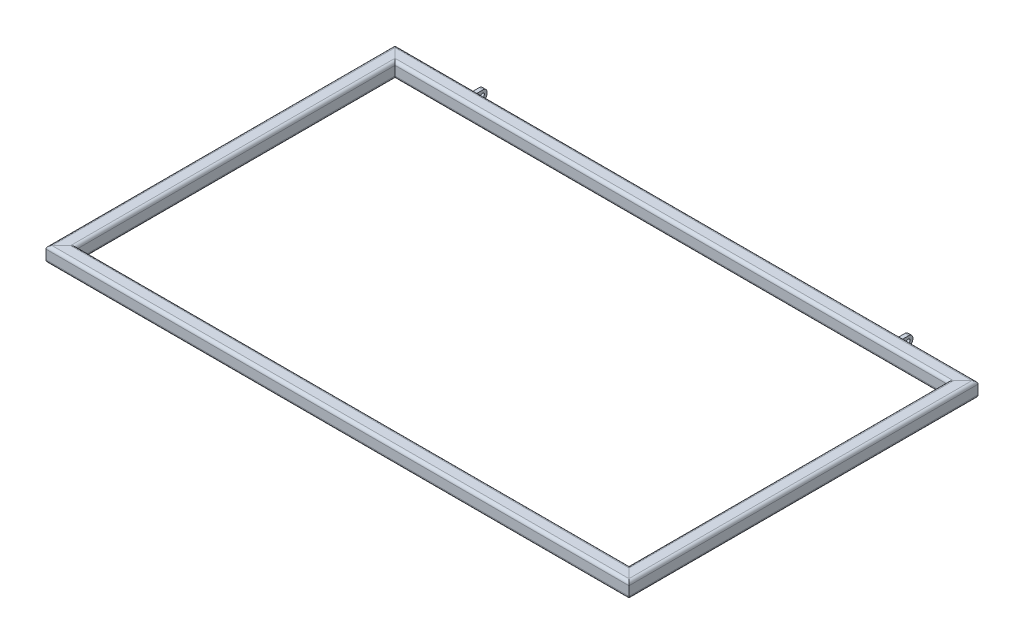
from build123d import *

# Parameters (mm, degrees)
SQUARE_TUBE_CONFIGURED_20_X_20_X_2_1_DEPTH      = 785.142135624
SQUARE_TUBE_CONFIGURED_20_X_20_X_2_1_DEPTH_BACK = 25.142135624
SQUARE_TUBE_CONFIGURED_20_X_20_X_2_1_2_DEPTH    = 505.284271247
SQUARE_TUBE_CONFIGURED_20_X_20_X_2_1_3_DEPTH    = 810.284271247
SQUARE_TUBE_CONFIGURED_20_X_20_X_2_1_4_DEPTH    = 505.284271247
SKETCH12_W                                      = 5
SKETCH12_H                                      = 12
BOSS_EXTRUDE1_DEPTH                             = 15
BOSS_EXTRUDE1_2_DEPTH                           = 15
FILLET1_R                                       = 5
FILLET2_R                                       = 5
SKETCH13_R                                      = 2.5
CUT_EXTRUDE1_DEPTH                              = 699.52075846
CUT_EXTRUDE1_DEPTH_BACK                         = 699.52075846


with BuildPart() as part:
    # Sketch11 → Square tube - configured 20 X 20 X 2(1) (new, two sides)
    with BuildSketch(Plane(origin=(380, 0, -217.5), x_dir=(0, 0, 1), z_dir=(-1, 0, 0))) as square_tube_configured_20_x_20_x_2_1_sk:
        with BuildLine():
            Line((-6, -10), (6, -10))
            ThreePointArc((6, -10), (8.828427125, -8.828427125), (10, -6))
            Line((10, -6), (10, 6))
            ThreePointArc((10, 6), (8.828427125, 8.828427125), (6, 10))
            Line((6, 10), (-6, 10))
            ThreePointArc((-6, 10), (-8.828427125, 8.828427125), (-10, 6))
            Line((-10, 6), (-10, -6))
            ThreePointArc((-10, -6), (-8.828427125, -8.828427125), (-6, -10))
        make_face()
        with BuildLine():
            Line((-6, -8), (6, -8))
            ThreePointArc((6, -8), (7.414213562, -7.414213562), (8, -6))
            Line((8, -6), (8, 6))
            ThreePointArc((8, 6), (7.414213562, 7.414213562), (6, 8))
            Line((6, 8), (-6, 8))
            ThreePointArc((-6, 8), (-7.414213562, 7.414213562), (-8, 6))
            Line((-8, 6), (-8, -6))
            ThreePointArc((-8, -6), (-7.414213562, -7.414213562), (-6, -8))
        make_face(mode=Mode.SUBTRACT)
    extrude(amount=SQUARE_TUBE_CONFIGURED_20_X_20_X_2_1_DEPTH)
    extrude(square_tube_configured_20_x_20_x_2_1_sk.sketch, amount=-SQUARE_TUBE_CONFIGURED_20_X_20_X_2_1_DEPTH_BACK)

    # Square tube - configured 20 X 20 X 2(1) m
    split(bisect_by=Plane(origin=(380, 0, -227.5), x_dir=(0, -1, 0), z_dir=(-0.707106781, 0, -0.707106781)), keep=Keep.TOP)

    # Square tube - configured 20 X 20 X 2 2
    split(bisect_by=Plane(origin=(-380, 0, -227.5), x_dir=(0, 1, 0), z_dir=(0.707106781, 0, -0.707106781)), keep=Keep.TOP)


with BuildPart() as body_2:
    # Sketch11 on segment 2 (carried to segment 2) → Square tube - configured 20 X 20 X 2_1 2 (new body)
    with BuildSketch(Plane(origin=(-370, 0, -252.642135624), x_dir=(1, 0, 0), z_dir=(0, 0, 1))):
        with BuildLine():
            Line((-6, -10), (6, -10))
            ThreePointArc((6, -10), (8.828427125, -8.828427125), (10, -6))
            Line((10, -6), (10, 6))
            ThreePointArc((10, 6), (8.828427125, 8.828427125), (6, 10))
            Line((6, 10), (-6, 10))
            ThreePointArc((-6, 10), (-8.828427125, 8.828427125), (-10, 6))
            Line((-10, 6), (-10, -6))
            ThreePointArc((-10, -6), (-8.828427125, -8.828427125), (-6, -10))
        make_face()
        with BuildLine():
            Line((-6, -8), (6, -8))
            ThreePointArc((6, -8), (7.414213562, -7.414213562), (8, -6))
            Line((8, -6), (8, 6))
            ThreePointArc((8, 6), (7.414213562, 7.414213562), (6, 8))
            Line((6, 8), (-6, 8))
            ThreePointArc((-6, 8), (-7.414213562, 7.414213562), (-8, 6))
            Line((-8, 6), (-8, -6))
            ThreePointArc((-8, -6), (-7.414213562, -7.414213562), (-6, -8))
        make_face(mode=Mode.SUBTRACT)
    extrude(amount=SQUARE_TUBE_CONFIGURED_20_X_20_X_2_1_2_DEPTH)

    # Square tube - configured 20 X 20 X 2 3
    split(bisect_by=Plane(origin=(-380, 0, 227.5), x_dir=(0, -1, 0), z_dir=(-0.707106781, 0, -0.707106781)), keep=Keep.TOP)

    # Square tube - configured 20 X 20 X 2 4
    split(bisect_by=Plane(origin=(-380, 0, -227.5), x_dir=(0, -1, 0), z_dir=(-0.707106781, 0, 0.707106781)), keep=Keep.TOP)


with BuildPart() as body_3:
    # Sketch11 on segment 3 (carried to segment 3) → Square tube - configured 20 X 20 X 2_1 3 (new body)
    with BuildSketch(Plane(origin=(-405.142135624, 0, 217.5), x_dir=(0, 0, -1), z_dir=(1, 0, 0))):
        with BuildLine():
            Line((-6, -10), (6, -10))
            ThreePointArc((6, -10), (8.828427125, -8.828427125), (10, -6))
            Line((10, -6), (10, 6))
            ThreePointArc((10, 6), (8.828427125, 8.828427125), (6, 10))
            Line((6, 10), (-6, 10))
            ThreePointArc((-6, 10), (-8.828427125, 8.828427125), (-10, 6))
            Line((-10, 6), (-10, -6))
            ThreePointArc((-10, -6), (-8.828427125, -8.828427125), (-6, -10))
        make_face()
        with BuildLine():
            Line((-6, -8), (6, -8))
            ThreePointArc((6, -8), (7.414213562, -7.414213562), (8, -6))
            Line((8, -6), (8, 6))
            ThreePointArc((8, 6), (7.414213562, 7.414213562), (6, 8))
            Line((6, 8), (-6, 8))
            ThreePointArc((-6, 8), (-7.414213562, 7.414213562), (-8, 6))
            Line((-8, 6), (-8, -6))
            ThreePointArc((-8, -6), (-7.414213562, -7.414213562), (-6, -8))
        make_face(mode=Mode.SUBTRACT)
    extrude(amount=SQUARE_TUBE_CONFIGURED_20_X_20_X_2_1_3_DEPTH)

    # Square tube - configured 20 X 20 X 2 5
    split(bisect_by=Plane(origin=(380, 0, 227.5), x_dir=(0, -1, 0), z_dir=(-0.707106781, 0, 0.707106781)), keep=Keep.TOP)

    # Square tube - configured 20 X 20 X 2 6
    split(bisect_by=Plane(origin=(-380, 0, 227.5), x_dir=(0, 1, 0), z_dir=(0.707106781, 0, 0.707106781)), keep=Keep.TOP)


with BuildPart() as body_4:
    # Sketch11 on segment 4 (carried to segment 4) → Square tube - configured 20 X 20 X 2_1 4 (new body)
    with BuildSketch(Plane(origin=(370, 0, 252.642135624), x_dir=(-1, 0, 0), z_dir=(0, 0, -1))):
        with BuildLine():
            Line((-6, -10), (6, -10))
            ThreePointArc((6, -10), (8.828427125, -8.828427125), (10, -6))
            Line((10, -6), (10, 6))
            ThreePointArc((10, 6), (8.828427125, 8.828427125), (6, 10))
            Line((6, 10), (-6, 10))
            ThreePointArc((-6, 10), (-8.828427125, 8.828427125), (-10, 6))
            Line((-10, 6), (-10, -6))
            ThreePointArc((-10, -6), (-8.828427125, -8.828427125), (-6, -10))
        make_face()
        with BuildLine():
            Line((-6, -8), (6, -8))
            ThreePointArc((6, -8), (7.414213562, -7.414213562), (8, -6))
            Line((8, -6), (8, 6))
            ThreePointArc((8, 6), (7.414213562, 7.414213562), (6, 8))
            Line((6, 8), (-6, 8))
            ThreePointArc((-6, 8), (-7.414213562, 7.414213562), (-8, 6))
            Line((-8, 6), (-8, -6))
            ThreePointArc((-8, -6), (-7.414213562, -7.414213562), (-6, -8))
        make_face(mode=Mode.SUBTRACT)
    extrude(amount=SQUARE_TUBE_CONFIGURED_20_X_20_X_2_1_4_DEPTH)

    # Square tube - configured 20 X 20 X 2 7
    split(bisect_by=Plane(origin=(380, 0, 227.5), x_dir=(0, 1, 0), z_dir=(0.707106781, 0, -0.707106781)), keep=Keep.TOP)

    # Square tube - configured 20 X 20 X 2 8
    split(bisect_by=Plane(origin=(380, 0, -227.5), x_dir=(0, 1, 0), z_dir=(0.707106781, 0, 0.707106781)), keep=Keep.TOP)


with BuildPart() as body_5:
    # Sketch12 → Boss-Extrude1 (new body)
    with BuildSketch(Plane(origin=(0, 0, -227.5), x_dir=(-1, 0, 0), z_dir=(0, 0, -1))):
        with Locations((-277.5, 0)):
            Rectangle(SKETCH12_W, SKETCH12_H)
    extrude(amount=BOSS_EXTRUDE1_DEPTH)

    # Fillet1
    fillet1_edges = [body_5.edges().sort_by_distance(p)[0] for p in [
        (277.5, 6, -242.5),
        (277.5, -6, -242.5),
    ]]
    fillet(fillet1_edges, radius=FILLET1_R)


with BuildPart() as body_6:
    # Sketch12 → Boss-Extrude1 2 (new body)
    with BuildSketch(Plane(origin=(0, 0, -227.5), x_dir=(-1, 0, 0), z_dir=(0, 0, -1))):
        with Locations((277.5, 0)):
            Rectangle(SKETCH12_W, SKETCH12_H)
    extrude(amount=BOSS_EXTRUDE1_2_DEPTH)

    # Fillet2
    fillet2_edges = [body_6.edges().sort_by_distance(p)[0] for p in [
        (-277.5, -6, -242.5),
        (-277.5, 6, -242.5),
    ]]
    fillet(fillet2_edges, radius=FILLET2_R)


with BuildPart() as cut_extrude1_tool:
    # Sketch13 → Cut-Extrude1 (new, two sides)
    with BuildSketch(Plane.ZY.offset(-275)) as cut_extrude1_sk:
        with Locations((-236.5, 0)):
            Circle(SKETCH13_R)
    extrude(amount=CUT_EXTRUDE1_DEPTH)
    extrude(cut_extrude1_sk.sketch, amount=-CUT_EXTRUDE1_DEPTH_BACK)


with BuildPart() as body_5_1:
    add(body_5.part)

    # Cut-Extrude1: cut by cut_extrude1_tool
    add(cut_extrude1_tool.part, mode=Mode.SUBTRACT)


with BuildPart() as body_6_1:
    add(body_6.part)

    # Cut-Extrude1: cut by cut_extrude1_tool
    add(cut_extrude1_tool.part, mode=Mode.SUBTRACT)


solid = Compound([part.part, body_2.part, body_3.part, body_4.part, body_5_1.part, body_6_1.part])
